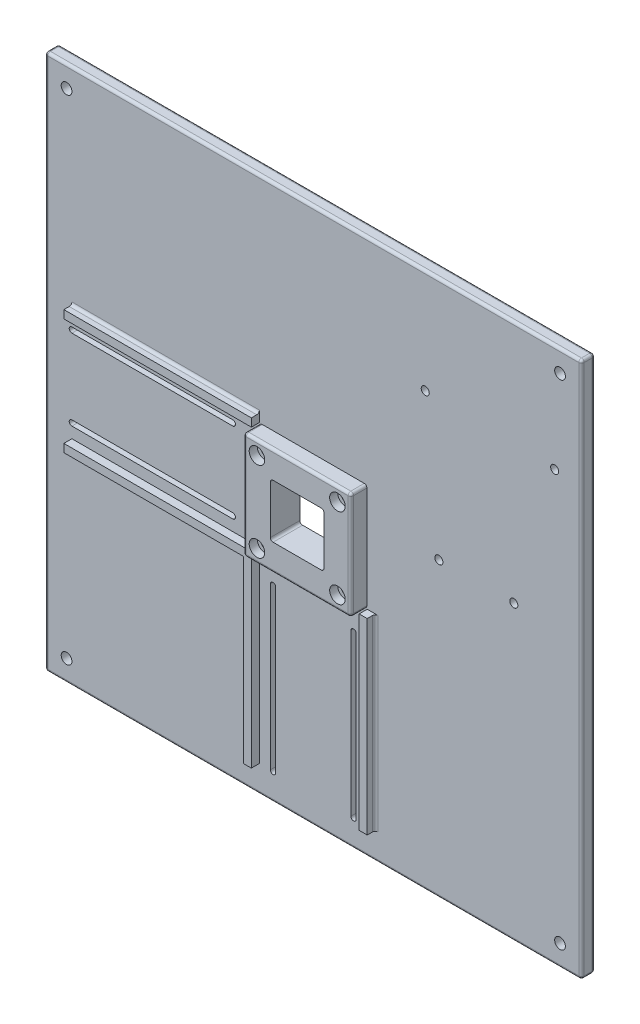
from build123d import *

# Parameters (mm, degrees)
ESQUISSE1_W                  = 200
ESQUISSE1_H                  = 200
BOSS_EXTRU_1_DEPTH           = 5
CONG_1_R                     = 1
ENL_V_MAT_EXTRU_4_REACH      = 7
ESQUISSE9_R                  = 2
ESQUISSE4_R                  = 1.5
ESQUISSE4_W                  = 20
ESQUISSE4_H                  = 20
ENL_V_MAT_EXTRU_5_DEPTH      = 1
ENL_V_MAT_EXTRU_5_DEPTH_BACK = 6
ESQUISSE11_W                 = 40
ESQUISSE11_H                 = 40
BOSS_EXTRU_3_DEPTH           = 6
CONG_2_R                     = 1
ESQUISSE12_R                 = 1.5
ENL_V_MAT_EXTRU_6_DEPTH      = 12
ESQUISSE13_R                 = 2.9
ENL_V_MAT_EXTRU_7_DEPTH      = 3
ENL_V_MAT_EXTRU_8_DEPTH      = 6
ESQUISSE15_W                 = 69.9
ESQUISSE15_H                 = 3
ESQUISSE15_W_2               = 3
ESQUISSE15_H_2               = 69.9
BOSS_EXTRU_4_DEPTH           = 3
CONG_3_R                     = 1
ESQUISSE20_R                 = 1.5
ENL_V_MAT_EXTRU_12_DEPTH     = 10


with BuildPart() as part:
    # Esquisse1 → Boss.-Extru.1 (new body)
    with BuildSketch(Plane.XY):
        Rectangle(ESQUISSE1_W, ESQUISSE1_H)
    extrude(amount=BOSS_EXTRU_1_DEPTH)

    # Congé1
    cong_1_edges = [part.edges().sort_by_distance(p)[0] for p in [
        (100, 0, 5),
        (0, 100, 5),
        (-100, 0, 5),
        (0, 100, 0),
        (100, 0, 0),
        (0, -100, 0),
        (-100, 0, 0),
        (-100, 100, 2.5),
        (100, 100, 2.5),
        (100, -100, 2.5),
        (-100, -100, 2.5),
        (0, -100, 5),
    ]]
    fillet(cong_1_edges, radius=CONG_1_R)

    # Esquisse9 → Enlèv. mat.-Extru.4 (cut, up to next)
    with BuildSketch(Plane(origin=(0, 0, 0), x_dir=(-1, 0, 0), z_dir=(0, 0, -1)), mode=Mode.PRIVATE) as enl_v_mat_extru_4_sk1:
        with Locations((-92, 92)):
            Circle(ESQUISSE9_R)
    enl_v_mat_extru_4_tool1 = extrude(enl_v_mat_extru_4_sk1.sketch, amount=-ENL_V_MAT_EXTRU_4_REACH, mode=Mode.PRIVATE) & part.part
    add(enl_v_mat_extru_4_tool1.solids().sort_by_distance((92, 92, 0))[0], mode=Mode.SUBTRACT)
    # Esquisse9 → Enlèv. mat.-Extru.4 (cut, up to next)
    with BuildSketch(Plane(origin=(0, 0, 0), x_dir=(-1, 0, 0), z_dir=(0, 0, -1)), mode=Mode.PRIVATE) as enl_v_mat_extru_4_sk2:
        with Locations((92, 92)):
            Circle(ESQUISSE9_R)
    enl_v_mat_extru_4_tool2 = extrude(enl_v_mat_extru_4_sk2.sketch, amount=-ENL_V_MAT_EXTRU_4_REACH, mode=Mode.PRIVATE) & part.part
    add(enl_v_mat_extru_4_tool2.solids().sort_by_distance((-92, 92, 0))[0], mode=Mode.SUBTRACT)
    # Esquisse9 → Enlèv. mat.-Extru.4 (cut, up to next)
    with BuildSketch(Plane(origin=(0, 0, 0), x_dir=(-1, 0, 0), z_dir=(0, 0, -1)), mode=Mode.PRIVATE) as enl_v_mat_extru_4_sk3:
        with Locations((92, -92)):
            Circle(ESQUISSE9_R)
    enl_v_mat_extru_4_tool3 = extrude(enl_v_mat_extru_4_sk3.sketch, amount=-ENL_V_MAT_EXTRU_4_REACH, mode=Mode.PRIVATE) & part.part
    add(enl_v_mat_extru_4_tool3.solids().sort_by_distance((-92, -92, 0))[0], mode=Mode.SUBTRACT)
    # Esquisse9 → Enlèv. mat.-Extru.4 (cut, up to next)
    with BuildSketch(Plane(origin=(0, 0, 0), x_dir=(-1, 0, 0), z_dir=(0, 0, -1)), mode=Mode.PRIVATE) as enl_v_mat_extru_4_sk4:
        with Locations((-92, -92)):
            Circle(ESQUISSE9_R)
    enl_v_mat_extru_4_tool4 = extrude(enl_v_mat_extru_4_sk4.sketch, amount=-ENL_V_MAT_EXTRU_4_REACH, mode=Mode.PRIVATE) & part.part
    add(enl_v_mat_extru_4_tool4.solids().sort_by_distance((92, -92, 0))[0], mode=Mode.SUBTRACT)

    # Esquisse4 → Enlèv. mat.-Extru.5 (cut, two sides)
    with BuildSketch(Plane.XY.offset(5)) as enl_v_mat_extru_5_sk:
        with Locations((-15, 15)):
            Circle(ESQUISSE4_R)
        with Locations((15, 15)):
            Circle(ESQUISSE4_R)
        with Locations((15, -15)):
            Circle(ESQUISSE4_R)
        with Locations((-15, -15)):
            Circle(ESQUISSE4_R)
        Rectangle(ESQUISSE4_W, ESQUISSE4_H)
    extrude(amount=ENL_V_MAT_EXTRU_5_DEPTH, mode=Mode.SUBTRACT)
    extrude(enl_v_mat_extru_5_sk.sketch, amount=-ENL_V_MAT_EXTRU_5_DEPTH_BACK, mode=Mode.SUBTRACT)

    # Esquisse11 → Boss.-Extru.3 (add)
    with BuildSketch(Plane.XY.offset(5)):
        Rectangle(ESQUISSE11_W, ESQUISSE11_H)
    extrude(amount=BOSS_EXTRU_3_DEPTH)

    # Congé2
    cong_2_edges = [part.edges().sort_by_distance(p)[0] for p in [
        (-20, -20, 8),
        (20, -20, 8),
        (0, 20, 11),
        (20, 20, 8),
        (-20, 0, 11),
        (-20, 20, 8),
        (0, -20, 11),
        (20, 0, 11),
        (-10, -10, 2.5),
        (-10, 10, 2.5),
        (10, 10, 2.5),
        (10, -10, 2.5),
    ]]
    fillet(cong_2_edges, radius=CONG_2_R)

    # Esquisse12 → Enlèv. mat.-Extru.6 (cut, through all)
    with BuildSketch(Plane.XY.offset(11)):
        with BuildLine():
            Line((10, -9), (10, 9))
            ThreePointArc((10, 9), (9.707106781, 9.707106781), (9, 10))
            Line((9, 10), (-9, 10))
            ThreePointArc((-9, 10), (-9.707106781, 9.707106781), (-10, 9))
            Line((-10, 9), (-10, -9))
            ThreePointArc((-10, -9), (-9.707106781, -9.707106781), (-9, -10))
            Line((-9, -10), (9, -10))
            ThreePointArc((9, -10), (9.707106781, -9.707106781), (10, -9))
        make_face()
        with Locations((15, 15)):
            Circle(ESQUISSE12_R)
        with Locations((-15, 15)):
            Circle(ESQUISSE12_R)
        with Locations((15, -15)):
            Circle(ESQUISSE12_R)
        with Locations((-15, -15)):
            Circle(ESQUISSE12_R)
    extrude(amount=-ENL_V_MAT_EXTRU_6_DEPTH, mode=Mode.SUBTRACT)

    # Esquisse13 → Enlèv. mat.-Extru.7 (cut)
    with BuildSketch(Plane.XY.offset(11)):
        with Locations((-15, 15)):
            Circle(ESQUISSE13_R)
        with Locations((15, 15)):
            Circle(ESQUISSE13_R)
        with Locations((15, -15)):
            Circle(ESQUISSE13_R)
        with Locations((-15, -15)):
            Circle(ESQUISSE13_R)
    extrude(amount=-ENL_V_MAT_EXTRU_7_DEPTH, mode=Mode.SUBTRACT)

    # Esquisse14 → Enlèv. mat.-Extru.8 (cut, through all)
    with BuildSketch(Plane.XY.offset(5)):
        with BuildLine():
            Line((-90, 16), (-30, 16))
            ThreePointArc((-30, 16), (-29, 15), (-30, 14))
            Line((-30, 14), (-90, 14))
            ThreePointArc((-90, 14), (-91, 15), (-90, 16))
        make_face()
        with BuildLine():
            Line((-30, -16), (-90, -16))
            ThreePointArc((-90, -16), (-91, -15), (-90, -14))
            Line((-90, -14), (-30, -14))
            ThreePointArc((-30, -14), (-29, -15), (-30, -16))
        make_face()
        with BuildLine():
            Line((16, -30), (16, -90))
            ThreePointArc((16, -90), (15, -91), (14, -90))
            Line((14, -90), (14, -30))
            ThreePointArc((14, -30), (15, -29), (16, -30))
        make_face()
        with BuildLine():
            Line((-16, -90), (-16, -30))
            ThreePointArc((-16, -30), (-15, -29), (-14, -30))
            Line((-14, -30), (-14, -90))
            ThreePointArc((-14, -90), (-15, -91), (-16, -90))
        make_face()
    extrude(amount=-ENL_V_MAT_EXTRU_8_DEPTH, mode=Mode.SUBTRACT)

    # Esquisse15 → Boss.-Extru.4 (add)
    with BuildSketch(Plane.XY.offset(5)):
        Polygon((-20.1, -20.1), (-20.1, -90), (-23.1, -90), (-23.1, -23.1), (-90, -23.1), (-90, -20.1), align=None)
        with Locations((-55.05, 21.6)):
            Rectangle(ESQUISSE15_W, ESQUISSE15_H)
        with Locations((21.6, -55.05)):
            Rectangle(ESQUISSE15_W_2, ESQUISSE15_H_2)
    extrude(amount=BOSS_EXTRU_4_DEPTH)

    # Congé3
    cong_3_edges = [part.edges().sort_by_distance(p)[0] for p in [
        (-55.05, 23.1, 5),
        (-56.55, -23.1, 5),
        (-23.1, -56.55, 5),
        (23.1, -55.05, 5),
    ]]
    fillet(cong_3_edges, radius=CONG_3_R)

    # Esquisse20 → Enlèv. mat.-Extru.12 (cut)
    with BuildSketch(Plane.XY.offset(5)):
        with Locations((46.82, 9.2)):
            Circle(ESQUISSE20_R)
        with Locations((41.74, 61.27)):
            Circle(ESQUISSE20_R)
        with Locations((90, 60)):
            Circle(ESQUISSE20_R)
        with Locations((74.76, 9.2)):
            Circle(ESQUISSE20_R)
    extrude(amount=-ENL_V_MAT_EXTRU_12_DEPTH, mode=Mode.SUBTRACT)


solid = part.part
